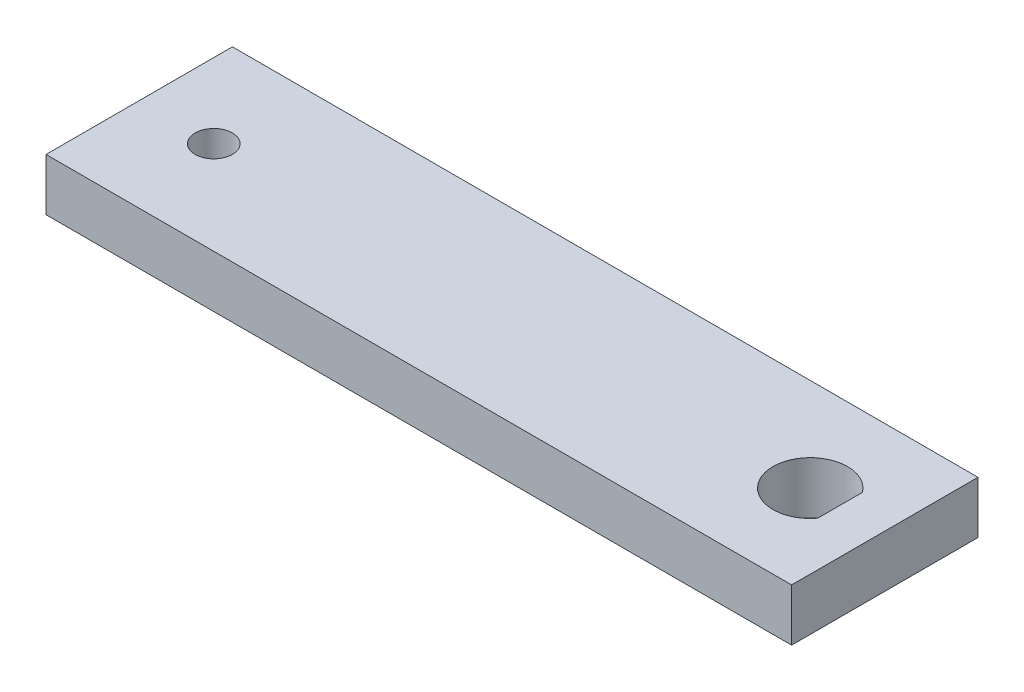
from build123d import *

# Parameters (mm, degrees)
SKETCH1_W          = 100
SKETCH1_H          = 7
BASE_EXTRUDE_DEPTH = 25
CUT_EXTRUDE1_DEPTH = 8
SKETCH3_R          = 2.5
CUT_EXTRUDE2_DEPTH = 8


with BuildPart() as part:
    # Sketch1 → Base-Extrude (new body)
    with BuildSketch(Plane.XY):
        with Locations((50, 3.5)):
            Rectangle(SKETCH1_W, SKETCH1_H)
    extrude(amount=BASE_EXTRUDE_DEPTH)

    # Sketch2 → Cut-Extrude1 (cut, through all)
    with BuildSketch(Plane(origin=(0, 7, 0), x_dir=(-1, 0, 0), z_dir=(0, 1, 0))):
        with BuildLine():
            Line((-94, 9.5), (-94, 15.5))
            ThreePointArc((-94, 15.5), (-85, 12.5), (-94, 9.5))
        make_face()
    extrude(amount=-CUT_EXTRUDE1_DEPTH, mode=Mode.SUBTRACT)

    # Sketch3 → Cut-Extrude2 (cut, through all)
    with BuildSketch(Plane(origin=(0, 7, 0), x_dir=(-1, 0, 0), z_dir=(0, 1, 0))):
        with Locations((-10, 12.5)):
            Circle(SKETCH3_R)
    extrude(amount=-CUT_EXTRUDE2_DEPTH, mode=Mode.SUBTRACT)


solid = part.part
